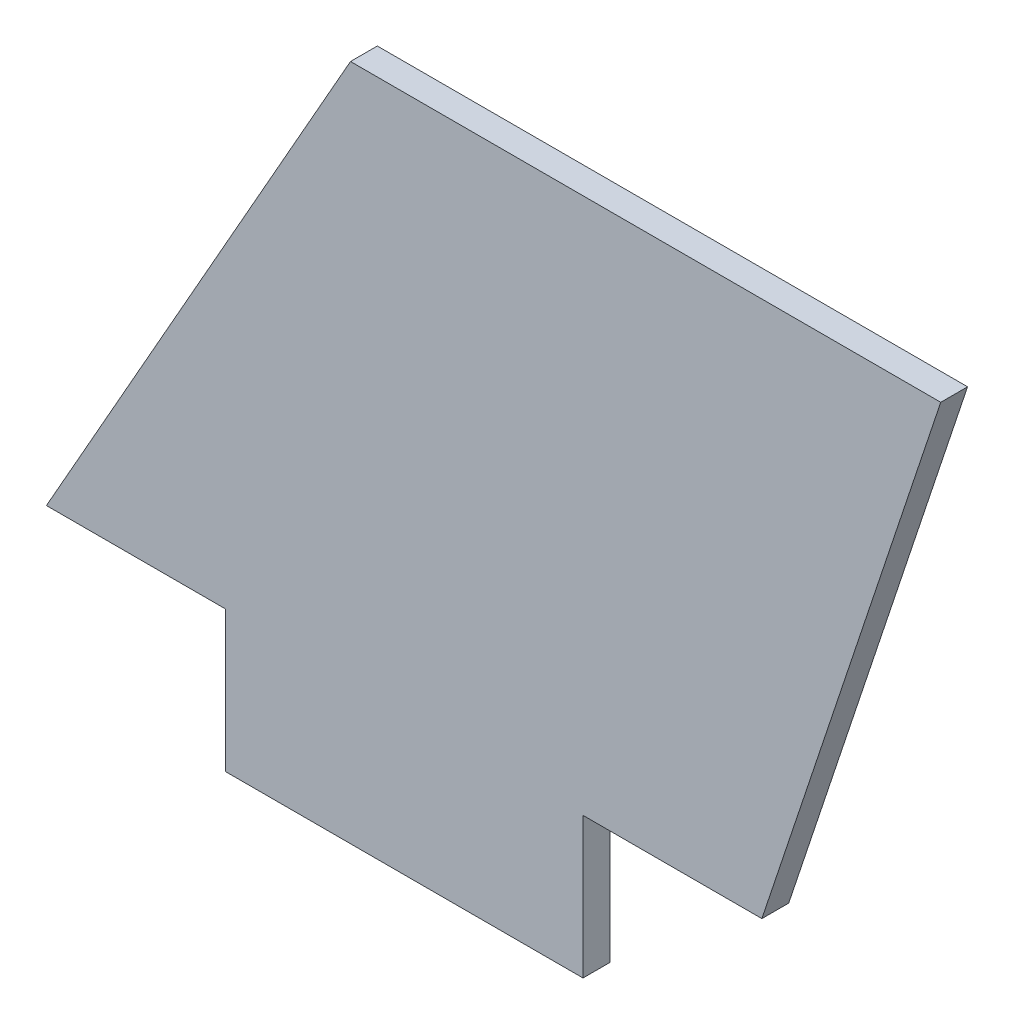
from build123d import *

# Parameters (mm, degrees)
BOSS_EXTRUDE1_DEPTH = 1.5


with BuildPart() as part:
    # Sketch1 → Boss-Extrude1 (new body)
    with BuildSketch(Plane.XY):
        Polygon((0, 0), (10, 0), (10, -7.875), (30, -7.875), (30, 0), (40, 0), (50, 30), (17, 30), align=None)
    extrude(amount=BOSS_EXTRUDE1_DEPTH)


solid = part.part
